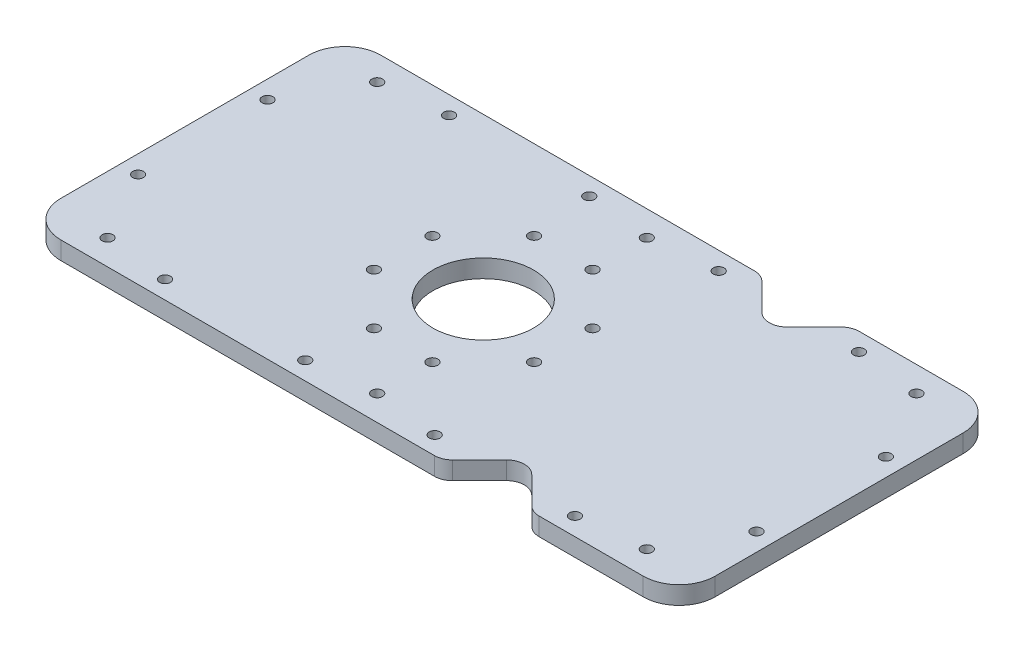
from build123d import *

# Parameters (mm, degrees)
SKETCH1_R           = 14
SKETCH1_R_2         = 1.5
BOSS_EXTRUDE1_DEPTH = 5


with BuildPart() as part:
    # Sketch1 → Boss-Extrude1 (new body)
    with BuildSketch(Plane(origin=(0, 0, 0), x_dir=(1, 0, 0), z_dir=(0, 1, 0))):
        with BuildLine():
            Line((26.464466094, -43.035533906), (33.964466094, -35.535533906))
            ThreePointArc((33.964466094, -35.535533906), (37.5, -34.071067812), (41.035533906, -35.535533906))
            Line((41.035533906, -35.535533906), (48.535533906, -43.035533906))
            ThreePointArc((48.535533906, -43.035533906), (50.15765065, -44.119397663), (52.071067812, -44.5))
            Line((52.071067812, -44.5), (81, -44.5))
            ThreePointArc((81, -44.5), (88.071067812, -41.571067812), (91, -34.5))
            Line((91, -34.5), (91, 34.5))
            ThreePointArc((91, 34.5), (88.071067812, 41.571067812), (81, 44.5))
            Line((81, 44.5), (52.071067812, 44.5))
            ThreePointArc((52.071067812, 44.5), (50.15765065, 44.119397663), (48.535533906, 43.035533906))
            Line((48.535533906, 43.035533906), (41.035533906, 35.535533906))
            ThreePointArc((41.035533906, 35.535533906), (37.5, 34.071067812), (33.964466094, 35.535533906))
            Line((33.964466094, 35.535533906), (26.464466094, 43.035533906))
            ThreePointArc((26.464466094, 43.035533906), (24.84234935, 44.119397663), (22.928932188, 44.5))
            Line((22.928932188, 44.5), (-81, 44.5))
            ThreePointArc((-81, 44.5), (-88.071067812, 41.571067812), (-91, 34.5))
            Line((-91, 34.5), (-91, -34.5))
            ThreePointArc((-91, -34.5), (-88.071067812, -41.571067812), (-81, -44.5))
            Line((-81, -44.5), (22.928932188, -44.5))
            ThreePointArc((22.928932188, -44.5), (24.84234935, -44.119397663), (26.464466094, -43.035533906))
        make_face()
        with Locations((-8, 0)):
            Circle(SKETCH1_R, mode=Mode.SUBTRACT)
        with Locations((-30.273863607, 8.131727984)):
            Circle(SKETCH1_R_2, mode=Mode.SUBTRACT)
        with Locations((-16.131727984, 22.273863607)):
            Circle(SKETCH1_R_2, mode=Mode.SUBTRACT)
        with Locations((0.131727984, 22.273863607)):
            Circle(SKETCH1_R_2, mode=Mode.SUBTRACT)
        with Locations((14.273863607, 8.131727984)):
            Circle(SKETCH1_R_2, mode=Mode.SUBTRACT)
        with Locations((14.273863607, -8.131727984)):
            Circle(SKETCH1_R_2, mode=Mode.SUBTRACT)
        with Locations((0.131727984, -22.273863607)):
            Circle(SKETCH1_R_2, mode=Mode.SUBTRACT)
        with Locations((-16.131727984, -22.273863607)):
            Circle(SKETCH1_R_2, mode=Mode.SUBTRACT)
        with Locations((-30.273863607, -8.131727984)):
            Circle(SKETCH1_R_2, mode=Mode.SUBTRACT)
        with Locations((-75, -37.5)):
            Circle(SKETCH1_R_2, mode=Mode.SUBTRACT)
        with Locations((-57, -39.5)):
            Circle(SKETCH1_R_2, mode=Mode.SUBTRACT)
        with Locations((-18, -39.5)):
            Circle(SKETCH1_R_2, mode=Mode.SUBTRACT)
        with Locations((0, -37.5)):
            Circle(SKETCH1_R_2, mode=Mode.SUBTRACT)
        with Locations((18, -39.5)):
            Circle(SKETCH1_R_2, mode=Mode.SUBTRACT)
        with Locations((57, -39.5)):
            Circle(SKETCH1_R_2, mode=Mode.SUBTRACT)
        with Locations((75, -37.5)):
            Circle(SKETCH1_R_2, mode=Mode.SUBTRACT)
        with Locations((86, -18)):
            Circle(SKETCH1_R_2, mode=Mode.SUBTRACT)
        with Locations((86, 18)):
            Circle(SKETCH1_R_2, mode=Mode.SUBTRACT)
        with Locations((75, 37.5)):
            Circle(SKETCH1_R_2, mode=Mode.SUBTRACT)
        with Locations((57, 39.5)):
            Circle(SKETCH1_R_2, mode=Mode.SUBTRACT)
        with Locations((18, 39.5)):
            Circle(SKETCH1_R_2, mode=Mode.SUBTRACT)
        with Locations((0, 37.5)):
            Circle(SKETCH1_R_2, mode=Mode.SUBTRACT)
        with Locations((-18, 39.5)):
            Circle(SKETCH1_R_2, mode=Mode.SUBTRACT)
        with Locations((-57, 39.5)):
            Circle(SKETCH1_R_2, mode=Mode.SUBTRACT)
        with Locations((-75, 37.5)):
            Circle(SKETCH1_R_2, mode=Mode.SUBTRACT)
        with Locations((-86, 18)):
            Circle(SKETCH1_R_2, mode=Mode.SUBTRACT)
        with Locations((-86, -18)):
            Circle(SKETCH1_R_2, mode=Mode.SUBTRACT)
    extrude(amount=BOSS_EXTRUDE1_DEPTH)


solid = part.part
